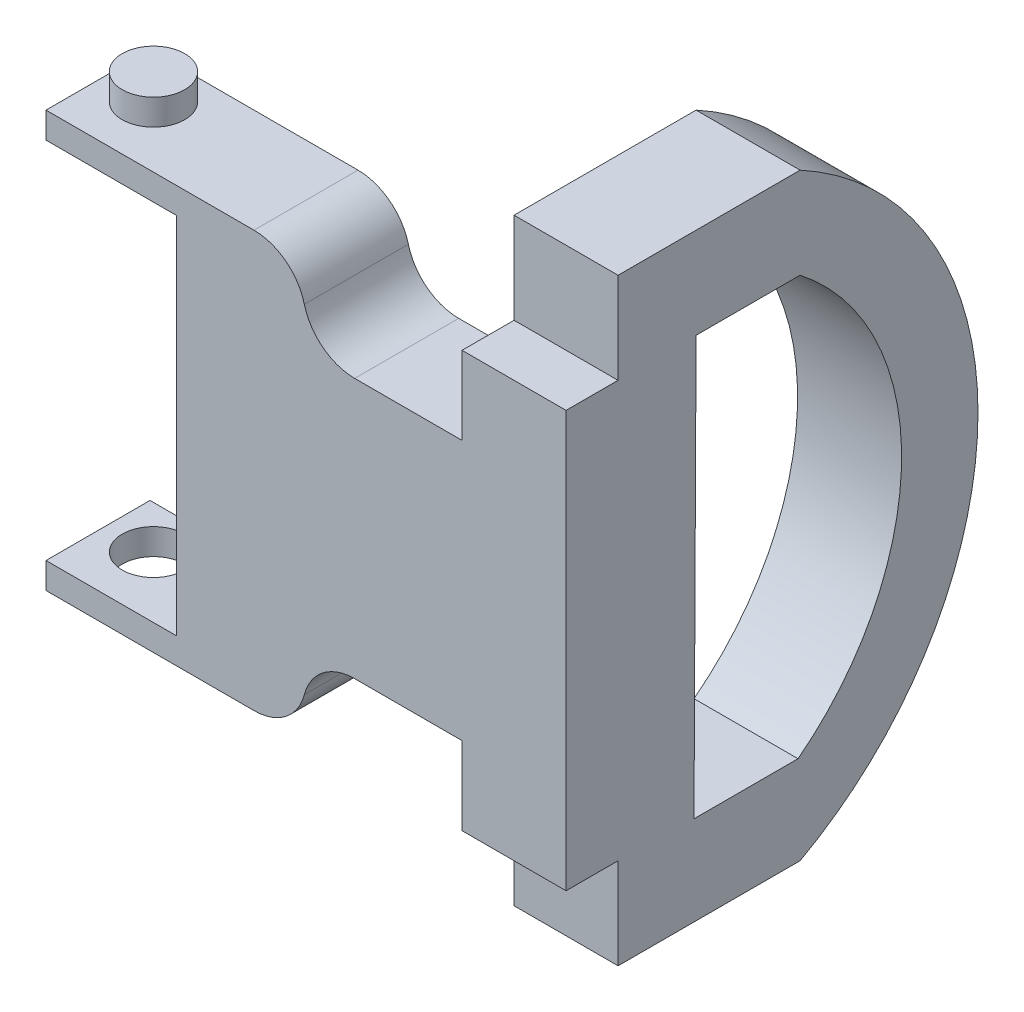
from build123d import *

# Parameters (mm, degrees)
BOSS_EXTRUDE3_DEPTH = 20
CUT_EXTRUDE3_DEPTH  = 20
BOSS_EXTRUDE4_DEPTH = 20
SKETCH5_W           = 10
SKETCH5_H           = 5
EXTRUDE_THIN1_DEPTH = 20
FILLET1_R           = 10
FILLET2_R           = 10
SKETCH6_R           = 6
CUT_EXTRUDE5_DEPTH  = 98.5
SKETCH7_W           = 25.027670854
SKETCH7_H           = 6.25
SKETCH7_W_2         = 25.066409398
CUT_EXTRUDE6_DEPTH  = 80.207653836
SKETCH8_R           = 6.011095122
BOSS_EXTRUDE6_DEPTH = 5
CUT_EXTRUDE9_DEPTH  = 35


with BuildPart() as part:
    # Sketch1 → Boss-Extrude3 (new body)
    with BuildSketch(Plane(origin=(0, 0, 0), x_dir=(0, 0, -1), z_dir=(1, 0, 0))):
        with BuildLine():
            Line((0, -17.661005955), (0, -97.661005955))
            Line((0, -97.661005955), (10, -97.661005955))
            Line((10, -97.661005955), (10, -115.161005955))
            Line((10, -115.161005955), (45, -115.161005955))
            ThreePointArc((45, -115.161005955), (79.207653836, -57.661005955), (45, -0.161005955))
            Line((45, -0.161005955), (10, -0.161005955))
            Line((10, -0.161005955), (10, -17.661005955))
            Line((10, -17.661005955), (0, -17.661005955))
        make_face()
    extrude(amount=BOSS_EXTRUDE3_DEPTH)

    # Sketch3 → Cut-Extrude3 (cut)
    with BuildSketch(Plane(origin=(20, 0, 0), x_dir=(0, 0, -1), z_dir=(1, 0, 0))):
        with BuildLine():
            Line((45, -17.661005955), (25, -17.661005955))
            Line((25, -17.661005955), (24.599094088, -97.970728365))
            Line((24.599094088, -97.970728365), (44.599094088, -97.970728365))
            ThreePointArc((44.599094088, -97.970728365), (64.519852612, -57.914310871), (45, -17.661005955))
        make_face()
    extrude(amount=-CUT_EXTRUDE3_DEPTH, mode=Mode.SUBTRACT)

    # Sketch4 → Boss-Extrude4 (add)
    with BuildSketch(Plane.XY):
        with BuildLine():
            Line((0, -17.661005955), (0, -32.661005955))
            Line((0, -32.661005955), (-20.64, -32.661005955))
            ThreePointArc((-20.64, -32.661005955), (-27.711067812, -29.732073767), (-30.64, -22.661005955))
            Line((-30.64, -22.661005955), (-40.64, -22.661005955))
            Line((-40.64, -22.661005955), (-40.64, -17.661005955))
            Line((-40.64, -17.661005955), (-80, -17.661005955))
            Line((-80, -17.661005955), (-79.933590602, -32.660858947))
            Line((-79.933590602, -32.660858947), (-54.933590602, -32.660858947))
            Line((-54.933590602, -32.660858947), (-54.933590602, -82.661005955))
            Line((-54.933590602, -82.661005955), (-80, -82.661005955))
            Line((-80, -82.661005955), (-80, -97.661005955))
            Line((-80, -97.661005955), (-40.64, -97.661005955))
            Line((-40.64, -97.661005955), (-40.64, -92.661005955))
            Line((-40.64, -92.661005955), (-30.64, -92.661005955))
            ThreePointArc((-30.64, -92.661005955), (-27.711067812, -85.589938143), (-20.64, -82.661005955))
            Line((-20.64, -82.661005955), (0, -82.661005955))
            Line((0, -82.661005955), (0, -97.661005955))
            Line((0, -97.661005955), (20, -97.661005955))
            Line((20, -97.661005955), (20, -17.661005955))
            Line((20, -17.661005955), (0, -17.661005955))
        make_face()
    extrude(amount=-BOSS_EXTRUDE4_DEPTH)

    # Sketch5 → Extrude-Thin1 (add)
    with BuildSketch(Plane.XY):
        with Locations((-35.64, -20.161005955)):
            Rectangle(SKETCH5_W, SKETCH5_H)
        with Locations((-35.64, -95.161005955)):
            Rectangle(SKETCH5_W, SKETCH5_H)
    extrude(amount=-EXTRUDE_THIN1_DEPTH)

    # Fillet1
    fillet1_edges = [part.edges().sort_by_distance(p)[0] for p in [
        (-30.64, -22.661005955, -10),
        (-30.64, -17.661005955, -10),
    ]]
    fillet(fillet1_edges, radius=FILLET1_R)

    # Fillet2
    fillet2_edges = [part.edges().sort_by_distance(p)[0] for p in [
        (-30.64, -97.661005955, -10),
        (-30.64, -92.661005955, -10),
    ]]
    fillet(fillet2_edges, radius=FILLET2_R)

    # Sketch6 → Cut-Extrude5 (cut, through all)
    with BuildSketch(Plane(origin=(0, -17.661005955, 0), x_dir=(1, 0, 0), z_dir=(0, 1, 0))):
        with Locations((-71.071972719, 11.735710253)):
            Circle(SKETCH6_R)
    extrude(amount=-CUT_EXTRUDE5_DEPTH, mode=Mode.SUBTRACT)

    # Sketch7 → Cut-Extrude6 (cut, through all)
    with BuildSketch(Plane.XY):
        with Locations((-67.447426029, -29.535858947)):
            Rectangle(SKETCH7_W, SKETCH7_H)
        with Locations((-67.466795301, -85.786005955)):
            Rectangle(SKETCH7_W_2, SKETCH7_H)
    extrude(amount=-CUT_EXTRUDE6_DEPTH, mode=Mode.SUBTRACT)

    # Sketch8 → Boss-Extrude6 (add)
    with BuildSketch(Plane(origin=(0, -17.661005955, 0), x_dir=(1, 0, 0), z_dir=(0, 1, 0))):
        with Locations((-71.071972719, 11.735710253)):
            Circle(SKETCH8_R)
    extrude(amount=BOSS_EXTRUDE6_DEPTH)

    # Sketch9 → Cut-Extrude9 (cut)
    with BuildSketch(Plane.XY):
        Polygon((-83.496027852, -22.661005955), (-54.933590602, -22.661005955), (-54.933590602, -92.661005955), (-84.905926437, -92.661005955), align=None)
    extrude(amount=-CUT_EXTRUDE9_DEPTH, mode=Mode.SUBTRACT)


solid = part.part
